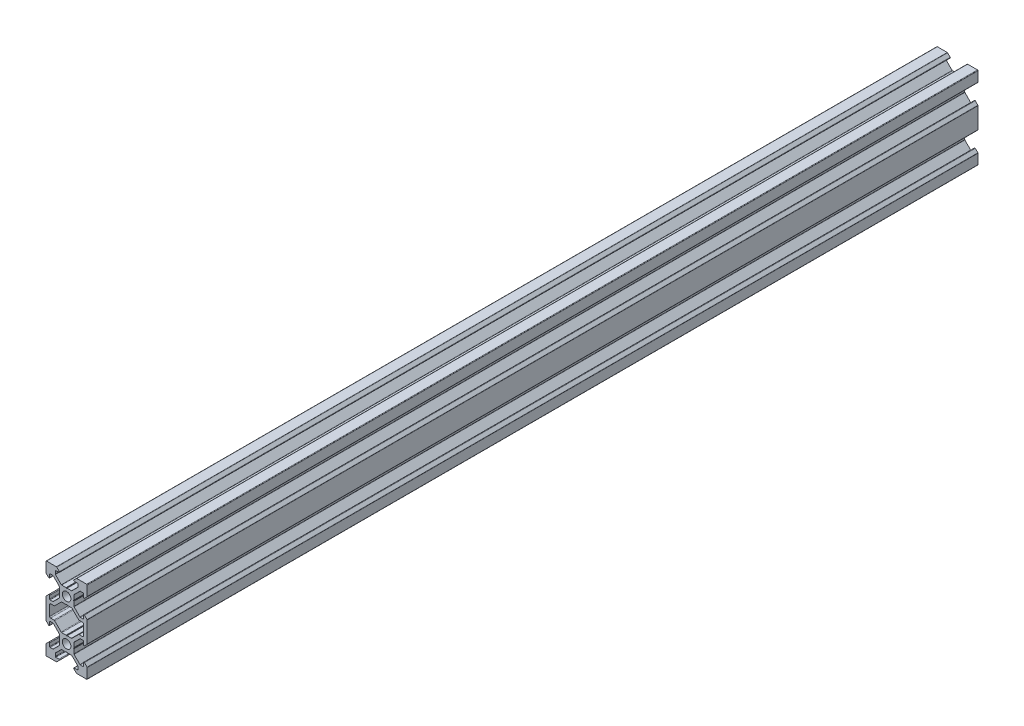
from build123d import *

# Parameters (mm, degrees)
SKETCH1_R           = 2.1
BOSS_EXTRUDE1_DEPTH = 432.69
FILLET1_R           = 0.25
FILLET2_R           = 0.5
CUT_EXTRUDE1_DEPTH  = 433.69


with BuildPart() as part:
    # Sketch1 → Boss-Extrude1 (new body)
    with BuildSketch(Plane.XY):
        Polygon((3.560660172, -2.5), (3.560660172, 2.5), (6.560660172, 5.5), (8.252142372, 5.5), (8.252142372, 3.1), (10, 4.847857628), (10, 10), (4.847857628, 10), (3.1, 8.252142372), (5.5, 8.252142372), (5.5, 6.560660172), (2.5, 3.560660172), (-2.5, 3.560660172), (-5.5, 6.560660172), (-5.5, 8.252142372), (-3.1, 8.252142372), (-4.847857628, 10), (-10, 10), (-10, 4.847857628), (-8.252142372, 3.1), (-8.252142372, 5.5), (-6.560660172, 5.5), (-3.560660172, 2.5), (-3.560660172, -2.5), (-6.560660172, -5.5), (-8.252142372, -5.5), (-8.252142372, -3.1), (-10, -4.847857628), (-10, -7), (-10, -13), (-10, -15.152142372), (-8.252142372, -16.9), (-8.252142372, -14.5), (-6.560660172, -14.5), (-3.560660172, -17.5), (-3.560660172, -22.5), (-6.560660172, -25.5), (-8.252142372, -25.5), (-8.252142372, -23.1), (-10, -24.847857628), (-10, -30), (-4.847857628, -30), (-3.1, -28.252142372), (-5.5, -28.252142372), (-5.5, -26.560660172), (-2.5, -23.560660172), (2.5, -23.560660172), (5.5, -26.560660172), (5.5, -28.252142372), (3.1, -28.252142372), (4.847857628, -30), (10, -30), (10, -24.847857628), (8.252142372, -23.1), (8.252142372, -25.5), (6.560660172, -25.5), (3.560660172, -22.5), (3.560660172, -17.5), (6.560660172, -14.5), (8.252142372, -14.5), (8.252142372, -16.9), (10, -15.152142372), (10, -13), (10, -7), (10, -4.847857628), (8.252142372, -3.1), (8.252142372, -5.5), (6.560660172, -5.5), align=None)
        Circle(SKETCH1_R, mode=Mode.SUBTRACT)
        with Locations((0, -20)):
            Circle(SKETCH1_R, mode=Mode.SUBTRACT)
        Polygon((2.5, -3.560660172), (-2.5, -3.560660172), (-5.5, -6.560660172), (-5.939339828, -7), (-8.252142372, -7), (-8.252142372, -13), (-5.939339828, -13), (-5.5, -13.439339828), (-2.5, -16.439339828), (2.5, -16.439339828), (5.5, -13.439339828), (5.939339828, -13), (8.252142372, -13), (8.252142372, -7), (5.939339828, -7), (5.5, -6.560660172), align=None, mode=Mode.SUBTRACT)
    extrude(amount=BOSS_EXTRUDE1_DEPTH)

    # Fillet1
    fillet1_edges = [part.edges().sort_by_distance(p)[0] for p in [
        (5.5, 6.560660172, 216.345),
        (5.5, 8.252142372, 216.345),
        (3.1, 8.252142372, 216.345),
        (4.847857628, 10, 216.345),
        (10, 10, 216.345),
        (10, 4.847857628, 216.345),
        (8.252142372, 3.1, 216.345),
        (8.252142372, 5.5, 216.345),
        (6.560660172, 5.5, 216.345),
        (3.560660172, 2.5, 216.345),
        (3.560660172, -2.5, 216.345),
        (6.560660172, -5.5, 216.345),
        (8.252142372, -5.5, 216.345),
        (8.252142372, -3.1, 216.345),
        (10, -4.847857628, 216.345),
        (10, -15.152142372, 216.345),
        (8.252142372, -16.9, 216.345),
        (8.252142372, -14.5, 216.345),
        (6.560660172, -14.5, 216.345),
        (3.560660172, -17.5, 216.345),
        (3.560660172, -22.5, 216.345),
        (6.560660172, -25.5, 216.345),
        (8.252142372, -25.5, 216.345),
        (8.252142372, -23.1, 216.345),
        (10, -24.847857628, 216.345),
        (10, -30, 216.345),
        (4.847857628, -30, 216.345),
        (3.1, -28.252142372, 216.345),
        (5.5, -28.252142372, 216.345),
        (5.5, -26.560660172, 216.345),
        (2.5, -23.560660172, 216.345),
        (-2.5, -23.560660172, 216.345),
        (-5.5, -26.560660172, 216.345),
        (-5.5, -28.252142372, 216.345),
        (-3.1, -28.252142372, 216.345),
        (-4.847857628, -30, 216.345),
        (-10, -30, 216.345),
        (-10, -24.847857628, 216.345),
        (-8.252142372, -23.1, 216.345),
        (-8.252142372, -25.5, 216.345),
        (-6.560660172, -25.5, 216.345),
        (-3.560660172, -22.5, 216.345),
        (-3.560660172, -17.5, 216.345),
        (-6.560660172, -14.5, 216.345),
        (-8.252142372, -14.5, 216.345),
        (-8.252142372, -16.9, 216.345),
        (-10, -15.152142372, 216.345),
        (-10, -4.847857628, 216.345),
        (-8.252142372, -3.1, 216.345),
        (-8.252142372, -5.5, 216.345),
        (-6.560660172, -5.5, 216.345),
        (-3.560660172, -2.5, 216.345),
        (-3.560660172, 2.5, 216.345),
        (-6.560660172, 5.5, 216.345),
        (-8.252142372, 5.5, 216.345),
        (-8.252142372, 3.1, 216.345),
        (-10, 4.847857628, 216.345),
        (-10, 10, 216.345),
        (-4.847857628, 10, 216.345),
        (-3.1, 8.252142372, 216.345),
        (-5.5, 8.252142372, 216.345),
        (-5.5, 6.560660172, 216.345),
        (-2.5, 3.560660172, 216.345),
        (2.5, 3.560660172, 216.345),
    ]]
    fillet(fillet1_edges, radius=FILLET1_R)

    # Fillet2
    fillet2_edges = [part.edges().sort_by_distance(p)[0] for p in [
        (-2.5, -3.560660172, 216.345),
        (-5.939339828, -7, 216.345),
        (-8.252142372, -7, 216.345),
        (-8.252142372, -13, 216.345),
        (-5.939339828, -13, 216.345),
        (-2.5, -16.439339828, 216.345),
        (2.5, -16.439339828, 216.345),
        (5.939339828, -13, 216.345),
        (8.252142372, -13, 216.345),
        (8.252142372, -7, 216.345),
        (5.939339828, -7, 216.345),
        (2.5, -3.560660172, 216.345),
    ]]
    fillet(fillet2_edges, radius=FILLET2_R)

    # Sketch2 → Cut-Extrude1 (cut, through all)
    with BuildSketch(Plane.XY.offset(432.69)):
        Polygon((0, 3.398953432), (-0.242280927, 3.560660172), (0.242280927, 3.560660172), align=None)
        Polygon((0, -3.398953432), (0.242280927, -3.560660172), (-0.242280927, -3.560660172), align=None)
        Polygon((3.560660172, 0.242280927), (3.560660172, -0.242280927), (3.398953432, 0), align=None)
        Polygon((-3.560660172, 0.242280927), (-3.560660172, -0.242280927), (-3.398953432, 0), align=None)
        Polygon((-3.398953432, -20), (-3.560660172, -20.242280927), (-3.560660172, -19.757719073), align=None)
        Polygon((3.398953432, -20), (3.560660172, -19.757719073), (3.560660172, -20.242280927), align=None)
        Polygon((-0.242280927, -16.439339828), (0.242280927, -16.439339828), (0, -16.601046568), align=None)
        Polygon((-0.242280927, -23.560660172), (0.242280927, -23.560660172), (0, -23.398953432), align=None)
    extrude(amount=-CUT_EXTRUDE1_DEPTH, mode=Mode.SUBTRACT)


solid = part.part
